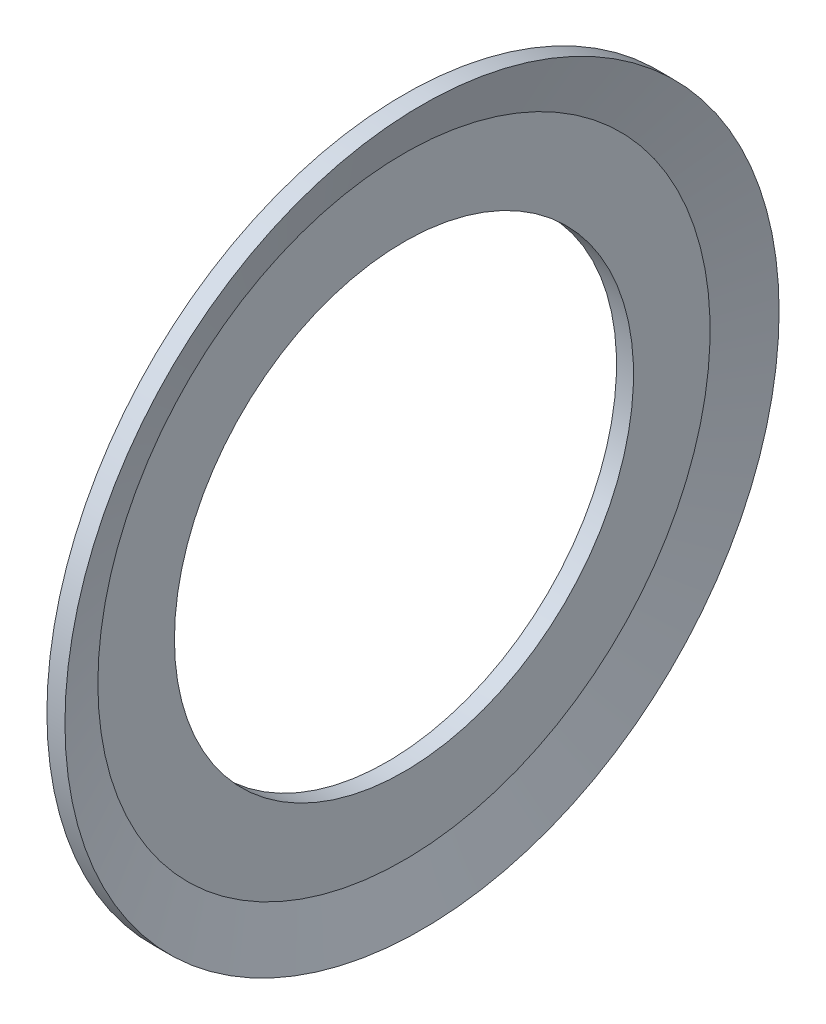
from build123d import *


with BuildPart() as part:
    # Esquisse1 → Base-Révolution (revolve)
    with BuildSketch(Plane.XY):
        Polygon((0, 13.5), (0, 18.175), (0.999830117, 21), (2.060613271, 21), (1, 18.003258415), (1, 13.5), align=None)
    revolve(axis=Axis((0, 0, 0), (1, 0, 0)))


solid = part.part
